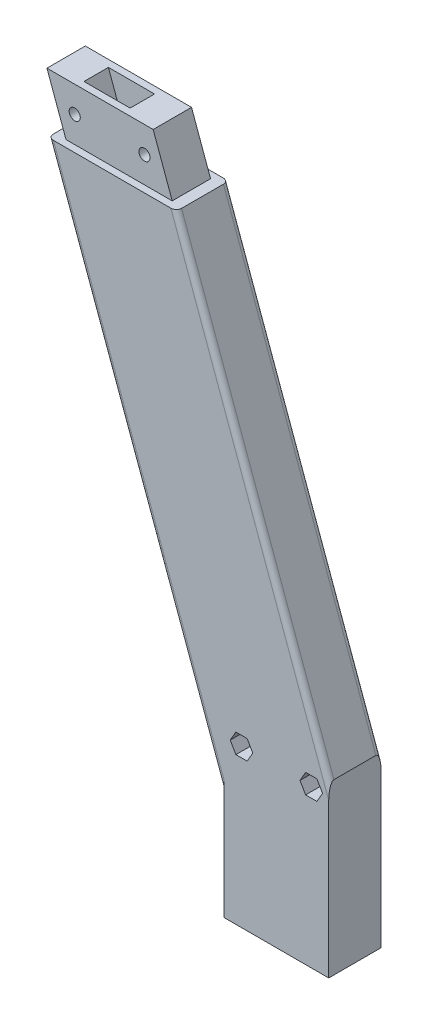
from build123d import *

# Parameters (mm, degrees)
SKETCH1_W            = 30
SKETCH1_H            = 48.5
SKETCH1_R            = 1.55
BOSS_EXTRUDE1_DEPTH  = 15
SKETCH1_3_R          = 6.5
CUT_EXTRUDE2_DEPTH   = 2
CUT_EXTRUDE3_DEPTH   = 4.5
BOSS_EXTRUDE2_DEPTH  = 15
CUT_EXTRUDE4_DEPTH   = 11
SKETCH2_5_R          = 1.6
BOSS_EXTRUDE4_DEPTH  = 13
SKETCH2_6_R          = 1.6
CUT_EXTRUDE5_DEPTH   = 2
CUT_EXTRUDE6_DEPTH   = 11
BOSS_EXTRUDE8_DEPTH  = 4
BOSS_EXTRUDE10_DEPTH = 4
CUT_EXTRUDE8_DEPTH   = 2
CUT_EXTRUDE9_REACH   = 17
FILLET1_R            = 1.5


with BuildPart() as part:
    # Sketch1 → Boss-Extrude1 (new body)
    with BuildSketch(Plane.XY):
        with Locations((15, 20.25)):
            Rectangle(SKETCH1_W, SKETCH1_H)
        with Locations((5, 40.95)):
            Circle(SKETCH1_R, mode=Mode.SUBTRACT)
        with Locations((25, 40.95)):
            Circle(SKETCH1_R, mode=Mode.SUBTRACT)
    extrude(amount=BOSS_EXTRUDE1_DEPTH)

    # Sketch1_3 → Cut-Extrude2 (cut)
    with BuildSketch(Plane.XY):
        with Locations((15, 8)):
            Circle(SKETCH1_3_R)
    extrude(amount=CUT_EXTRUDE2_DEPTH, mode=Mode.SUBTRACT)

    # Sketch4 → Cut-Extrude3 (cut)
    with BuildSketch(Plane.XY.offset(15)):
        Polygon((8.233161507, 40.95), (6.616580754, 43.75), (3.383419246, 43.75), (1.766838493, 40.95), (3.383419246, 38.15), (6.616580754, 38.15), align=None)
        Polygon((28.233161507, 40.95), (26.616580754, 43.75), (23.383419246, 43.75), (21.766838493, 40.95), (23.383419246, 38.15), (26.616580754, 38.15), align=None)
    extrude(amount=-CUT_EXTRUDE3_DEPTH, mode=Mode.SUBTRACT)

    # Sketch2 → Boss-Extrude2 (add)
    with BuildSketch(Plane.XY):
        Polygon((-25.480933218, 164.5), (18.195494894, 44.5), (30, 44.5), (-13.676428112, 164.5), (-16.868961429, 164.5), align=None)
        Polygon((-32.092545942, 164.5), (-38.704158666, 164.5), (4.972269446, 44.5), (18.195494894, 44.5), (-25.480933218, 164.5), align=None)
        Polygon((-47.316130455, 164.5), (0, 34.5), (0, 44.5), (4.972269446, 44.5), (-38.704158666, 164.5), align=None)
        Polygon((-3.192533317, 34.5), (0, 34.5), (-47.316130455, 164.5), (-50.508663772, 164.5), align=None)
        Polygon((0, 25.7285868), (0, 34.5), (-3.192533317, 34.5), align=None)
    extrude(amount=BOSS_EXTRUDE2_DEPTH)

    # Sketch2_3 → Cut-Extrude4 (cut)
    with BuildSketch(Plane.XY):
        Polygon((-32.092545942, 164.5), (-38.704158666, 164.5), (4.972269446, 44.5), (18.195494894, 44.5), (-25.480933218, 164.5), align=None)
        Polygon((-41.433935423, 172), (-38.704158666, 164.5), (-32.092545942, 164.5), (-34.822322699, 172), align=None)
        Polygon((-37.552099456, 179.5), (-44.16371218, 179.5), (-42.022322699, 173.616580754), (-41.433935423, 172), (-34.822322699, 172), align=None)
        Polygon((-30.940486732, 179.5), (-37.552099456, 179.5), (-34.822322699, 172), (-28.210709975, 172), align=None)
        Polygon((-34.822322699, 172), (-32.092545942, 164.5), (-25.480933218, 164.5), (-27.622322699, 170.383419246), (-28.210709975, 172), align=None)
    extrude(amount=CUT_EXTRUDE4_DEPTH, mode=Mode.SUBTRACT)

    # Sketch2_5 → Boss-Extrude4 (add)
    with BuildSketch(Plane.XY):
        Polygon((-52.775683969, 179.5), (-47.316130455, 164.5), (-16.868961429, 164.5), (-22.328514943, 179.5), align=None)
        with Locations((-44.822322699, 172)):
            Circle(SKETCH2_5_R, mode=Mode.SUBTRACT)
        with Locations((-24.822322699, 172)):
            Circle(SKETCH2_5_R, mode=Mode.SUBTRACT)
    extrude(amount=BOSS_EXTRUDE4_DEPTH)

    # Sketch2_6 → Cut-Extrude5 (cut)
    with BuildSketch(Plane.XY):
        Polygon((-52.775683969, 179.5), (-47.316130455, 164.5), (-16.868961429, 164.5), (-22.328514943, 179.5), align=None)
        with Locations((-44.822322699, 172)):
            Circle(SKETCH2_6_R, mode=Mode.SUBTRACT)
        with Locations((-24.822322699, 172)):
            Circle(SKETCH2_6_R, mode=Mode.SUBTRACT)
    extrude(amount=CUT_EXTRUDE5_DEPTH, mode=Mode.SUBTRACT)

    # Sketch2_7 → Cut-Extrude6 (cut)
    with BuildSketch(Plane.XY):
        Polygon((-37.552099456, 179.5), (-44.16371218, 179.5), (-42.022322699, 173.616580754), (-41.433935423, 172), (-34.822322699, 172), align=None)
        Polygon((-41.433935423, 172), (-38.704158666, 164.5), (-32.092545942, 164.5), (-34.822322699, 172), align=None)
        Polygon((-34.822322699, 172), (-32.092545942, 164.5), (-25.480933218, 164.5), (-27.622322699, 170.383419246), (-28.210709975, 172), align=None)
        Polygon((-30.940486732, 179.5), (-37.552099456, 179.5), (-34.822322699, 172), (-28.210709975, 172), align=None)
    extrude(amount=CUT_EXTRUDE6_DEPTH, mode=Mode.SUBTRACT)

    # Sketch2_9 → Boss-Extrude8 (add)
    with BuildSketch(Plane.XY):
        Polygon((-32.092545942, 164.5), (-38.704158666, 164.5), (4.972269446, 44.5), (18.195494894, 44.5), (-25.480933218, 164.5), align=None)
    extrude(amount=BOSS_EXTRUDE8_DEPTH)

    # Sketch2_11 → Boss-Extrude10 (add)
    with BuildSketch(Plane.XY):
        Polygon((-41.433935423, 172), (-38.704158666, 164.5), (-32.092545942, 164.5), (-34.822322699, 172), align=None)
        Polygon((-37.552099456, 179.5), (-44.16371218, 179.5), (-42.022322699, 173.616580754), (-41.433935423, 172), (-34.822322699, 172), align=None)
        Polygon((-34.822322699, 172), (-32.092545942, 164.5), (-25.480933218, 164.5), (-27.622322699, 170.383419246), (-28.210709975, 172), align=None)
        Polygon((-30.940486732, 179.5), (-37.552099456, 179.5), (-34.822322699, 172), (-28.210709975, 172), align=None)
    extrude(amount=BOSS_EXTRUDE10_DEPTH)

    # Sketch2_12 → Cut-Extrude8 (cut)
    with BuildSketch(Plane.XY):
        Polygon((-37.552099456, 179.5), (-44.16371218, 179.5), (-42.022322699, 173.616580754), (-41.433935423, 172), (-34.822322699, 172), align=None)
        Polygon((-41.433935423, 172), (-38.704158666, 164.5), (-32.092545942, 164.5), (-34.822322699, 172), align=None)
        Polygon((-34.822322699, 172), (-32.092545942, 164.5), (-25.480933218, 164.5), (-27.622322699, 170.383419246), (-28.210709975, 172), align=None)
        Polygon((-30.940486732, 179.5), (-37.552099456, 179.5), (-34.822322699, 172), (-28.210709975, 172), align=None)
    extrude(amount=CUT_EXTRUDE8_DEPTH, mode=Mode.SUBTRACT)

    # Sketch6 → Cut-Extrude9 (cut, up to next)
    with BuildSketch(Plane(origin=(0, 0, 0), x_dir=(-1, 0, 0), z_dir=(0, 0, -1)), mode=Mode.PRIVATE) as cut_extrude9_sk1:
        Polygon((-18.195494894, 44.5), (-4.972269446, 44.5), (0.487284068, 59.5), (-12.73594138, 59.5), align=None)
    cut_extrude9_tool1 = extrude(cut_extrude9_sk1.sketch, amount=-CUT_EXTRUDE9_REACH, mode=Mode.PRIVATE) & part.part
    add(cut_extrude9_tool1.solids().sort_by_distance((8.854105, 52, 0))[0], mode=Mode.SUBTRACT)

    # Fillet1
    fillet1_edges = [part.edges().sort_by_distance(p)[0] for p in [
        (-25.254331886, 95.1142934, 0),
        (8.161785944, 104.5, 0),
        (-25.254331886, 95.1142934, 15),
        (8.161785944, 104.5, 15),
    ]]
    fillet(fillet1_edges, radius=FILLET1_R)


solid = part.part
